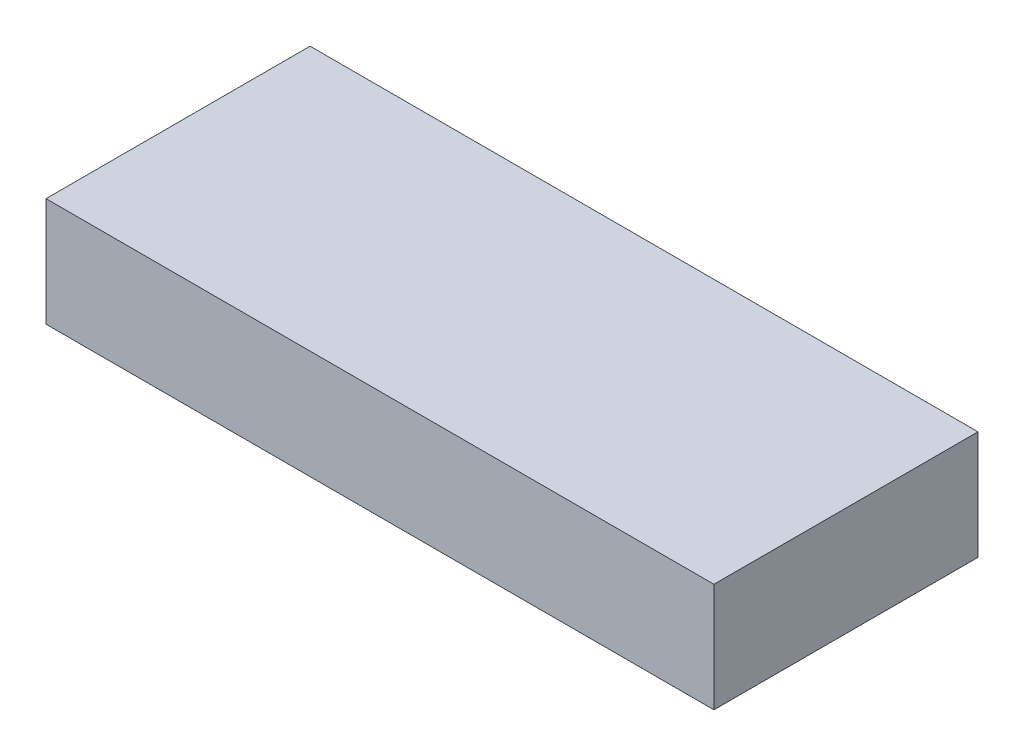
from build123d import *

# Parameters (mm, degrees)
SKETCH1_W           = 43
SKETCH1_H           = 17
BOSS_EXTRUDE1_DEPTH = 7


with BuildPart() as part:
    # Sketch1 → Boss-Extrude1 (new body)
    with BuildSketch(Plane(origin=(0, 0, 0), x_dir=(1, 0, 0), z_dir=(0, 1, 0))):
        with Locations((21.5, 8.5)):
            Rectangle(SKETCH1_W, SKETCH1_H)
    extrude(amount=BOSS_EXTRUDE1_DEPTH)


solid = part.part
